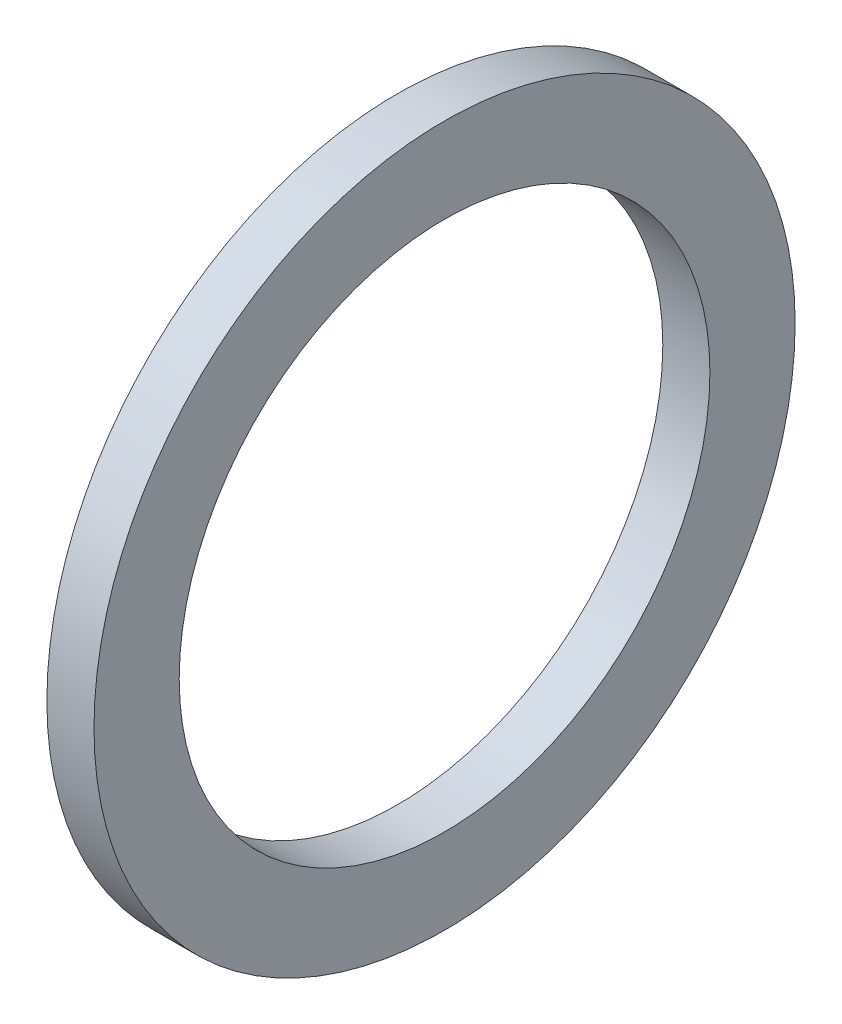
from build123d import *

# Parameters (mm, degrees)
SKETCH1_R           = 6.4262
SKETCH1_R_2         = 4.8641
BOSS_EXTRUDE1_DEPTH = 0.8636


with BuildPart() as part:
    # Sketch1 → Boss-Extrude1 (new body)
    with BuildSketch(Plane(origin=(0, 0, 0), x_dir=(0, 0, -1), z_dir=(1, 0, 0))):
        Circle(SKETCH1_R)
        Circle(SKETCH1_R_2, mode=Mode.SUBTRACT)
    extrude(amount=BOSS_EXTRUDE1_DEPTH)


solid = part.part
